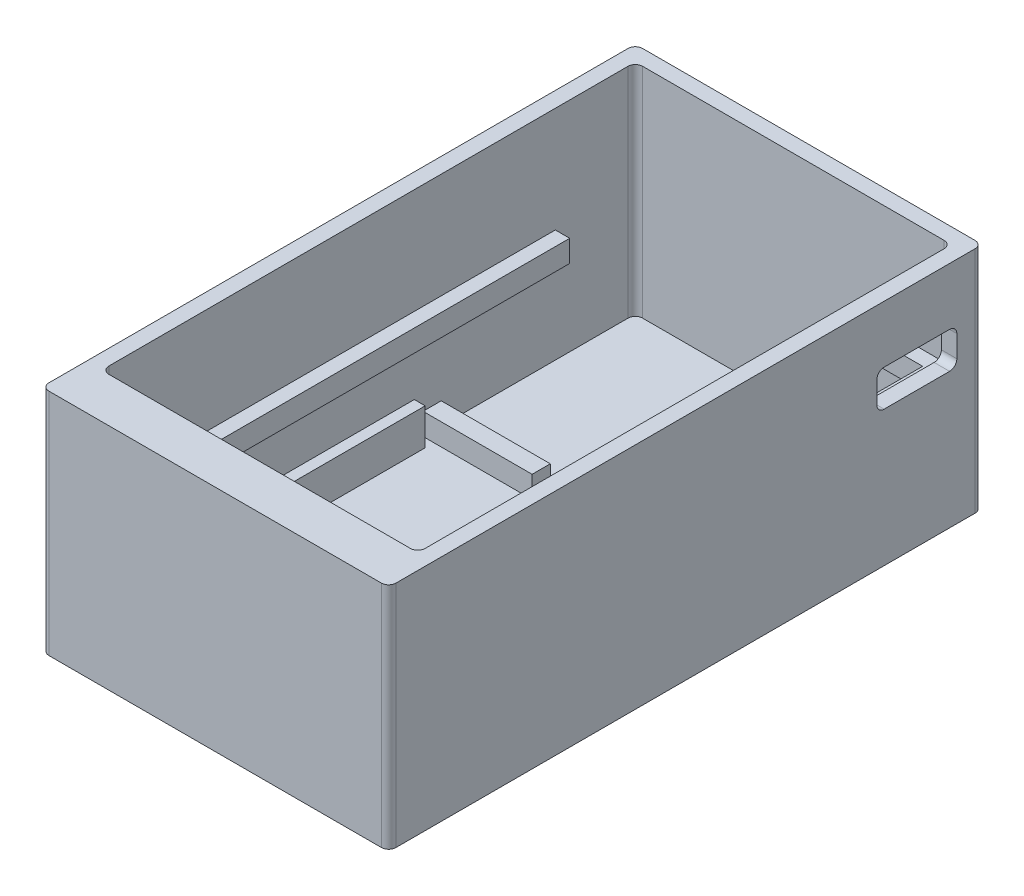
from build123d import *

# Parameters (mm, degrees)
PCB_DIMENSIONS_W    = 47.716732244
PCB_DIMENSIONS_H    = 81.636732244
BOSS_EXTRUDE3_DEPTH = 1.5
SKETCH5_W           = 47.716732244
SKETCH5_H           = 81.636732244
SKETCH5_W_2         = 43.474091557
SKETCH5_H_2         = 73.394091557
BOSS_EXTRUDE5_DEPTH = 30
FILLET1_R           = 1
SKETCH9_W           = 1.93805105
SKETCH9_H           = 42
SKETCH9_W_2         = 1.938051049
BOSS_EXTRUDE6_DEPTH = 5
SKETCH14_W          = 15
SKETCH14_H          = 2.5
BOSS_EXTRUDE7_DEPTH = 3
SKETCH15_W          = 79.636732244
SKETCH15_H          = 3
BOSS_EXTRUDE8_DEPTH = 46
SKETCH17_W          = 39.522771214
SKETCH17_H          = 62.982276128
CUT_EXTRUDE1_DEPTH  = 3
CUT_EXTRUDE2_DEPTH  = 3
SKETCH19_W          = 11
SKETCH19_H          = 5
CUT_EXTRUDE3_DEPTH  = 10
FILLET2_R           = 1
SCALE1_SCALE        = 0.99


with BuildPart() as part:
    # PCB Dimensions → Boss-Extrude3 (new body)
    with BuildSketch(Plane(origin=(0, 0, 0), x_dir=(1, 0, 0), z_dir=(0, 1, 0))):
        with Locations((20.322832216, -37.282832216)):
            Rectangle(PCB_DIMENSIONS_W, PCB_DIMENSIONS_H)
    extrude(amount=BOSS_EXTRUDE3_DEPTH)

    # Sketch5 → Boss-Extrude5 (add)
    with BuildSketch(Plane(origin=(0, 1.5, 0), x_dir=(1, 0, 0), z_dir=(0, 1, 0))):
        with Locations((20.322832216, -37.282832216)):
            Rectangle(SKETCH5_W, SKETCH5_H)
        with Locations((20.322832217, -35.282832217)):
            Rectangle(SKETCH5_W_2, SKETCH5_H_2, mode=Mode.SUBTRACT)
    extrude(amount=BOSS_EXTRUDE5_DEPTH)

    # Fillet1
    fillet1_edges = [part.edges().sort_by_distance(p)[0] for p in [
        (42.059877995, 16.5, -1.414213562),
        (-1.414213562, 16.5, -1.414213562),
        (-1.414213562, 16.5, 71.979877995),
        (42.059877995, 16.5, 71.979877995),
        (44.181198338, 15.75, 78.101198338),
        (-3.535533906, 15.75, 78.101198338),
        (-3.535533906, 15.75, -3.535533906),
        (44.181198338, 15.75, -3.535533906),
    ]]
    fillet(fillet1_edges, radius=FILLET1_R)

    # Sketch9 → Boss-Extrude6 (add)
    with BuildSketch(Plane(origin=(0, 1.5, 0), x_dir=(1, 0, 0), z_dir=(0, 1, 0))):
        with Locations((-0.88911969, -49.979881394)):
            Rectangle(SKETCH9_W, SKETCH9_H)
        with Locations((41.534784122, -49.979881394)):
            Rectangle(SKETCH9_W_2, SKETCH9_H)
    extrude(amount=BOSS_EXTRUDE6_DEPTH)

    # Sketch14 → Boss-Extrude7 (add)
    with BuildSketch(Plane(origin=(0, 1.5, 0), x_dir=(1, 0, 0), z_dir=(0, 1, 0))):
        with Locations((6.085786438, -26.529881394)):
            Rectangle(SKETCH14_W, SKETCH14_H)
        with Locations((34.559877995, -26.529881394)):
            Rectangle(SKETCH14_W, SKETCH14_H)
    extrude(amount=BOSS_EXTRUDE7_DEPTH)

    # Sketch15 → Boss-Extrude8 (add)
    with BuildSketch(Plane(origin=(44.181198338, 0, 0), x_dir=(0, 0, -1), z_dir=(1, 0, 0))):
        with Locations((-37.282832216, 15.5)):
            Rectangle(SKETCH15_W, SKETCH15_H)
    extrude(amount=-BOSS_EXTRUDE8_DEPTH)

    # Sketch17 → Cut-Extrude1 (cut)
    with BuildSketch(Plane(origin=(0, 17, 0), x_dir=(1, 0, 0), z_dir=(0, 1, 0))):
        with Locations((20.322832216, -32.052584673)):
            Rectangle(SKETCH17_W, SKETCH17_H)
    extrude(amount=-CUT_EXTRUDE1_DEPTH, mode=Mode.SUBTRACT)

    # Sketch18 → Cut-Extrude2 (cut)
    with BuildSketch(Plane(origin=(0, 17, 0), x_dir=(1, 0, 0), z_dir=(0, 1, 0))):
        with BuildLine():
            Line((-1.414213562, -9.585786438), (28.585786438, -9.585786438))
            Line((28.585786438, -9.585786438), (28.585786438, 1.414213562))
            Line((28.585786438, 1.414213562), (-0.414213562, 1.414213562))
            ThreePointArc((-0.414213562, 1.414213562), (-1.121320344, 1.121320344), (-1.414213562, 0.414213562))
            Line((-1.414213562, 0.414213562), (-1.414213562, -9.585786438))
        make_face()
    extrude(amount=-CUT_EXTRUDE2_DEPTH, mode=Mode.SUBTRACT)

    # Sketch19 → Cut-Extrude3 (cut)
    with BuildSketch(Plane(origin=(44.181198338, 0, 0), x_dir=(0, 0, -1), z_dir=(1, 0, 0))):
        with Locations((-5.464466094, 21.15)):
            Rectangle(SKETCH19_W, SKETCH19_H)
    extrude(amount=-CUT_EXTRUDE3_DEPTH, mode=Mode.SUBTRACT)

    # Fillet2
    fillet2_edges = [part.edges().sort_by_distance(p)[0] for p in [
        (43.120538167, 23.65, -0.035533906),
        (43.120538167, 18.65, -0.035533906),
        (43.120538167, 18.65, 10.964466094),
        (43.120538167, 23.65, 10.964466094),
    ]]
    fillet(fillet2_edges, radius=FILLET2_R)


with BuildPart() as part_1:
    # Scale1: scaled about (20.311867002, 12.9416955, 45.018687776)
    add(part.part.scale(SCALE1_SCALE).moved(Location((0.20311867, 0.129416955, 0.450186878))))


solid = part_1.part
